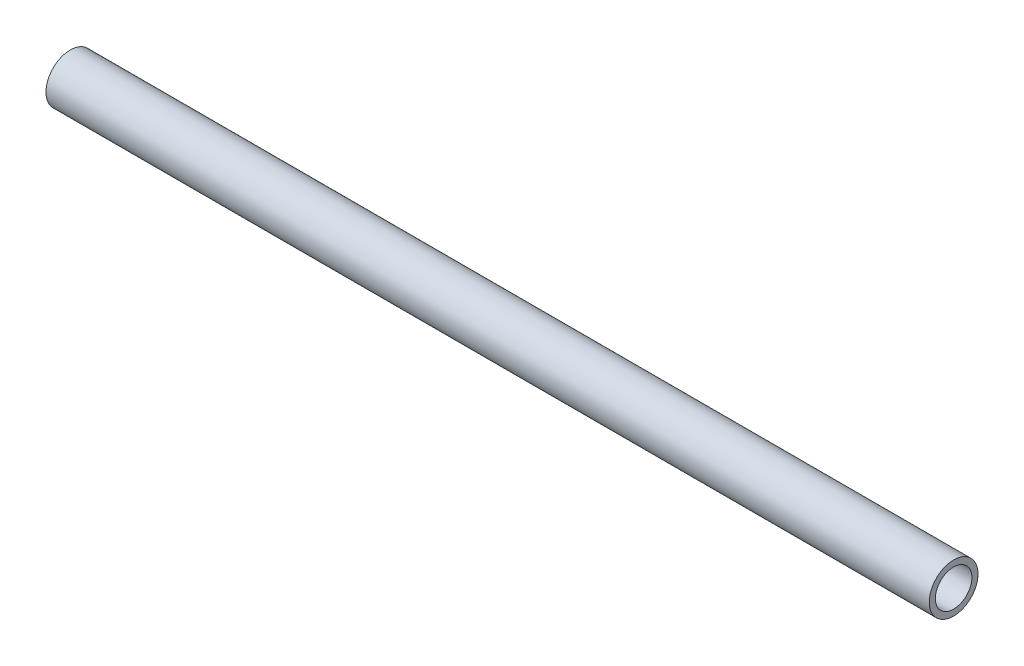
from build123d import *

# Parameters (mm, degrees)
SKETCH1_R           = 8
SKETCH1_R_2         = 6
BOSS_EXTRUDE1_DEPTH = 145


with BuildPart() as part:
    # Sketch1 → Boss-Extrude1 (new body, symmetric)
    with BuildSketch(Plane(origin=(0, 0, 0), x_dir=(0, 0, -1), z_dir=(1, 0, 0))):
        Circle(SKETCH1_R)
        Circle(SKETCH1_R_2, mode=Mode.SUBTRACT)
    extrude(amount=BOSS_EXTRUDE1_DEPTH, both=True)


solid = part.part
